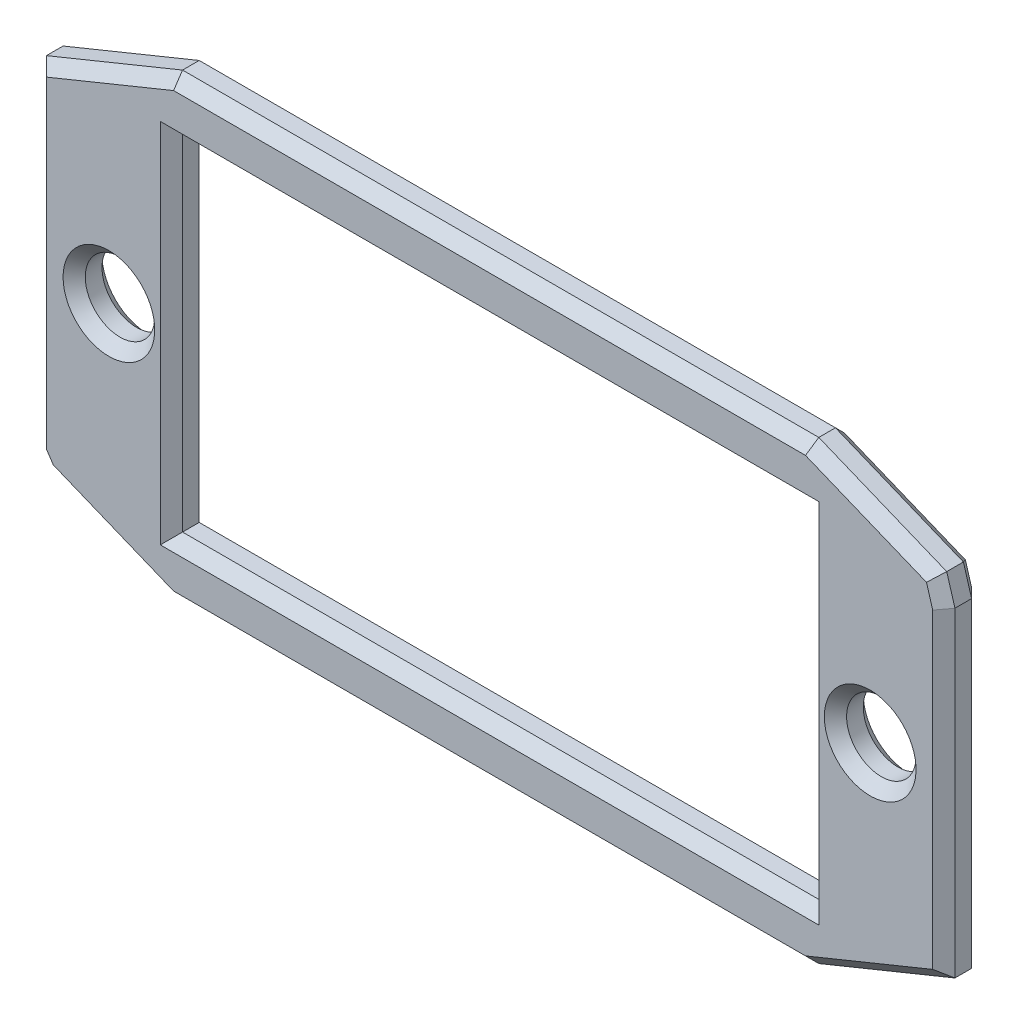
from build123d import *

# Parameters (mm, degrees)
SKETCH4_R           = 1.2500000000000009
SKETCH4_R_2         = 1.2499999999999993
BOSS_EXTRUDE1_DEPTH = 1.4
CHAMFER1_SIZE       = 0.4


with BuildPart() as part:
    # Sketch4 → Boss-Extrude1 (new body)
    # profile 1 of 8: a face of its own
    with BuildSketch(Plane(origin=(-1.7e-16, 0, 1.4000000000000032), x_dir=(-1, 0, -1.2e-16), z_dir=(1.2e-16, 0, -1))):
        Polygon((-7.546190091207485, 10.174212835332735), (-7.046190091207492, 10.174212835332735), (15.853809908792503, 10.174212835332744), (16.35380990879248, 10.174212835332744), (16.35380990879248, 10.674212835332737), (-7.546190091207485, 10.674212835332732), align=None)
    # profile 2 of 8: a face of its own
    with BuildSketch(Plane(origin=(-1.7e-16, 0, 1.4000000000000032), x_dir=(-1, 0, -1.2e-16), z_dir=(1.2e-16, 0, -1))):
        Polygon((-11.686815091207489, 10.17421283533274), (-7.546190091207485, 10.174212835332735), (-7.546190091207485, 10.674212835332732), (16.35380990879248, 10.674212835332737), (16.35380990879248, 10.174212835332744), (20.7538099087925, 10.17421283533274), (15.853809908792503, 12.174212835332744), (-7.046190091207496, 12.174212835332744), (-11.65105221022055, 10.294677276551901), align=None)
    # profile 3 of 8: a face of its own
    with BuildSketch(Plane(origin=(-1.7e-16, 0, 1.4000000000000032), x_dir=(-1, 0, -1.2e-16), z_dir=(1.2e-16, 0, -1))):
        with BuildLine():
            Line((16.35380990879248, 10.174212835332744), (16.353809908792496, -2.225787164667265))
            Line((16.353809908792496, -2.225787164667266), (20.4739831765189, -2.2257871646672647))
            ThreePointArc((20.473983176518885, -2.2257871646672385), (20.614466316717532, -2.0161736201746514), (20.753809908793457, -1.8058008223556463))
            Line((20.753809908792505, -1.805800822355394), (20.7538099087925, 10.17421283533274))
            Line((20.7538099087925, 10.17421283533274), (16.35380990879248, 10.174212835332744))
        make_face()
        with Locations(Location((18.103809908792506, 3.9742128353327333, 0), (0, 0, 180))):
            Circle(SKETCH4_R, mode=Mode.SUBTRACT)
    # profile 4 of 8: a face of its own
    with BuildSketch(Plane(origin=(-1.7e-16, 0, 1.4000000000000032), x_dir=(-1, 0, -1.2e-16), z_dir=(1.2e-16, 0, -1))):
        with BuildLine():
            Line((-7.54619009120748, -2.7257871646672593), (-7.54619009120748, -2.225787164667266))
            Line((-7.54619009120748, -2.225787164667266), (-11.946190091207495, -2.225787164667265))
            Line((-11.946190091207495, -2.225787164667265), (-7.046190091207487, -4.225787164667266))
            Line((-7.046190091207487, -4.225787164667266), (15.853809908792512, -4.225787164667266))
            Line((15.85380990879251, -4.225787164667266), (20.36710720596046, -2.383625002557896))
            ThreePointArc((20.367107205960004, -2.3836250025573023), (20.420626069676963, -2.3047608484368673), (20.473983176518885, -2.2257871646672385))
            Line((20.4739831765189, -2.2257871646672647), (16.353809908792496, -2.225787164667266))
            Line((16.353809908792496, -2.225787164667265), (16.353809908792496, -2.7257871646672562))
            Line((16.353809908792496, -2.725787164667256), (-7.546190091207482, -2.7257871646672593))
        make_face()
    # profile 5 of 8: a face of its own
    with BuildSketch(Plane(origin=(-1.7e-16, 0, 1.4000000000000032), x_dir=(-1, 0, -1.2e-16), z_dir=(1.2e-16, 0, -1))):
        Polygon((15.853809908792512, -2.225787164667266), (-7.046190091207487, -2.225787164667266), (-7.54619009120748, -2.225787164667266), (-7.54619009120748, -2.7257871646672593), (16.353809908792496, -2.725787164667256), (16.353809908792496, -2.225787164667265), align=None)
    # profile 6 of 8: a face of its own
    with BuildSketch(Plane(origin=(-1.7e-16, 0, 1.4000000000000032), x_dir=(-1, 0, -1.2e-16), z_dir=(1.2e-16, 0, -1))):
        Polygon((-11.946190091207495, -2.225787164667265), (-7.54619009120748, -2.225787164667266), (-7.546190091207485, 10.174212835332735), (-11.686815091207489, 10.17421283533274), (-11.946190091207496, 9.300528624806402), align=None)
        with Locations(Location((-9.296190091207496, 3.9742128353327333, 0), (0, 0, 180))):
            Circle(SKETCH4_R_2, mode=Mode.SUBTRACT)
    # profile 7 of 8: a face of its own
    with BuildSketch(Plane(origin=(-1.7e-16, 0, 1.4000000000000032), x_dir=(-1, 0, -1.2e-16), z_dir=(1.2e-16, 0, -1))):
        Polygon((15.853809908792503, 10.174212835332742), (15.85380990879251, -2.225787164667266), (16.353809908792496, -2.225787164667266), (16.35380990879248, 10.174212835332744), align=None)
    # profile 8 of 8: a face of its own
    with BuildSketch(Plane(origin=(-1.7e-16, 0, 1.4000000000000032), x_dir=(-1, 0, -1.2e-16), z_dir=(1.2e-16, 0, -1))):
        Polygon((-7.54619009120748, -2.225787164667266), (-7.046190091207487, -2.225787164667266), (-7.046190091207492, 10.174212835332735), (-7.546190091207485, 10.174212835332735), align=None)
    extrude(amount=BOSS_EXTRUDE1_DEPTH)

    # Chamfer1
    chamfer1_edges = [part.edges().sort_by_distance(p)[0] for p in [
        (8.046190091207496, 3.974212835332733, 1.4000000000000041),
        (-19.353809908792506, 3.974212835332733, 1.4000000000000008),
        (-4.403809908792507, 10.17421283533274, 1.4000000000000028),
        (7.04619009120749, 3.974212835332734, 1.4000000000000041),
        (-4.403809908792514, -2.2257871646672656, 1.4000000000000028),
        (-15.853809908792506, 3.9742128353327377, 1.4000000000000012),
        (11.798621150714023, 9.797602950679153, 1.4000000000000048),
        (9.348621150714022, 11.234445055942324, 1.4000000000000044),
        (-4.403809908792503, 12.174212835332744, 1.4000000000000028),
        (-18.303809908792502, 11.174212835332742, 1.400000000000001),
        (-20.753809908792505, 4.184206006488673, 1.4000000000000008),
        (-20.56153855062731, -2.095435686482624, 1.4000000000000008),
        (-18.110458557376482, -3.3047060836125812, 1.400000000000001),
        (-4.403809908792512, -4.225787164667266, 1.4000000000000028),
        (9.496190091207492, -3.2257871646672656, 1.4000000000000044),
        (11.946190091207495, 3.5373707300695685, 1.4000000000000048),
        (11.798621150714023, 9.797602950679153, 4.78e-15),
        (7.04619009120749, 3.974212835332734, 4.19e-15),
        (-4.40380990879251, -2.2257871646672656, 2.79e-15),
        (-15.853809908792506, 3.9742128353327377, 1.39e-15),
        (8.046190091207496, 3.974212835332733, 4.32e-15),
        (-19.353809908792506, 3.974212835332733, 9.6e-16),
        (9.348621150714022, 11.234445055942324, 4.48e-15),
        (-4.403809908792503, 12.174212835332744, 2.79e-15),
        (-18.303809908792502, 11.174212835332742, 1.09e-15),
        (-20.753809908792505, 4.184206006488673, 7.9e-16),
        (-20.56153855062727, -2.095435686482599, 8.1e-16),
        (-18.110458557376482, -3.3047060836125812, 1.11e-15),
        (-4.403809908792512, -4.225787164667266, 2.79e-15),
        (9.496190091207492, -3.2257871646672656, 4.49e-15),
        (11.946190091207495, 3.5373707300695685, 4.79e-15),
        (-4.403809908792507, 10.17421283533274, 2.79e-15),
    ]]
    chamfer(chamfer1_edges, length=CHAMFER1_SIZE)


solid = part.part
